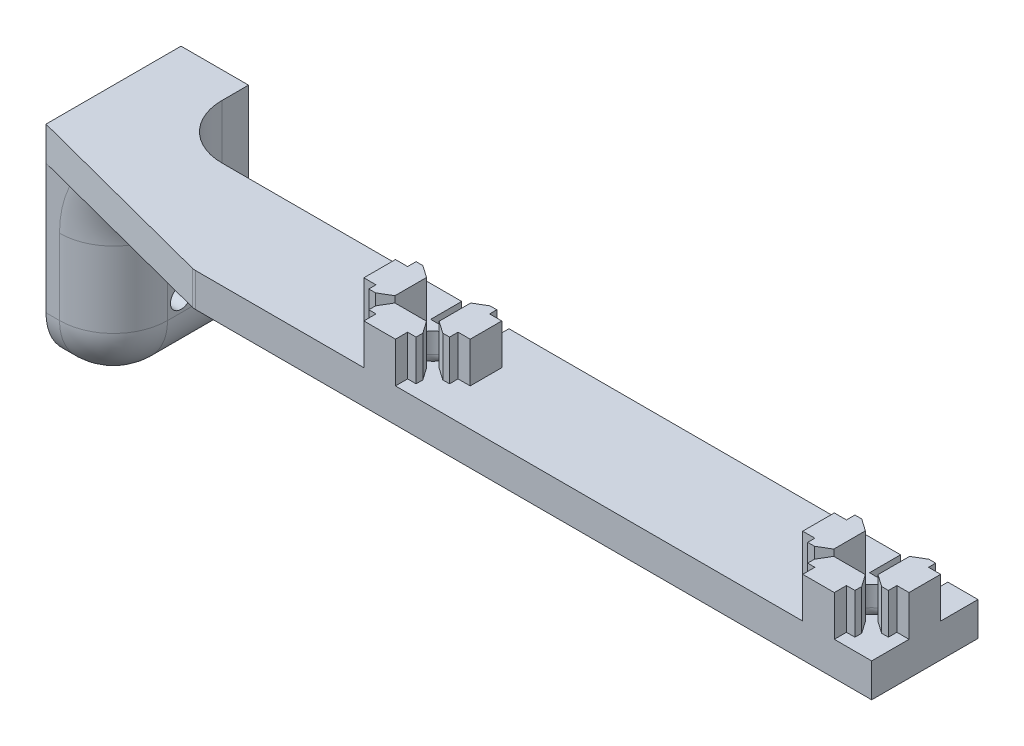
from build123d import *

# Parameters (mm, degrees)
BOSS_EXTRUDE1_DEPTH   = 7.62
BOSS_EXTRUDE1_2_DEPTH = 7.62
BOSS_EXTRUDE1_3_DEPTH = 7.62
BOSS_EXTRUDE1_4_DEPTH = 7.62
SKETCH2_W             = 165.1
SKETCH2_H             = 20
BOSS_EXTRUDE2_DEPTH   = 6.35
LPATTERN2_COUNT       = 2
LPATTERN2_PITCH       = 82.55
CUT_EXTRUDE1_DEPTH    = 157.048617104
FILLET1_R             = 2.54
SKETCH13_R            = 3.5
CUT_EXTRUDE5_DEPTH    = 156.608722121
FILLET6_R             = 2.54
SKETCH14_W            = 8.89
SKETCH14_H            = 5.842
CUT_EXTRUDE6_DEPTH    = 157.048617104
SKETCH15_W            = 25.4
SKETCH15_H            = 40.894
BOSS_EXTRUDE3_DEPTH   = 12.7
FILLET15_R            = 10.16
FILLET16_R            = 10.16
FILLET17_R            = 10.16
FILLET18_R            = 10.16
SKETCH18_R            = 1.984375
CUT_EXTRUDE9_DEPTH    = 12.7


with BuildPart() as part:
    # Sketch1 → Boss-Extrude1 (new body)
    with BuildSketch(Plane(origin=(0, 0, 0), x_dir=(1, 0, 0), z_dir=(0, 1, 0))):
        Polygon((2.9718, 10), (-2.9718, 10), (-2.9718, 7.714), (-4.567901235, 7.714), (-4.567901235, 6.444), (-2.9718, 4.158), (2.9718, 4.158), (4.322098765, 6.444), (4.322098765, 7.714), (2.9718, 7.714), align=None)
    boss_extrude1 = extrude(amount=BOSS_EXTRUDE1_DEPTH)



with BuildPart() as body_2:
    # Sketch1 → Boss-Extrude1 2 (new body)
    with BuildSketch(Plane(origin=(0, 0, 0), x_dir=(1, 0, 0), z_dir=(0, 1, 0))):
        Polygon((4.158, -2.9718), (4.158, 2.9718), (6.444, 4.322098765), (7.714, 4.322098765), (7.714, 2.9718), (10, 2.9718), (10, -2.9718), (7.714, -2.9718), (7.714, -4.567901235), (6.444, -4.567901235), align=None)
    boss_extrude1_2 = extrude(amount=BOSS_EXTRUDE1_2_DEPTH)


with BuildPart() as body_3:
    # Sketch1 → Boss-Extrude1 3 (new body)
    with BuildSketch(Plane(origin=(0, 0, 0), x_dir=(1, 0, 0), z_dir=(0, 1, 0))):
        Polygon((-10, -2.9718), (-10, 2.9718), (-7.714, 2.9718), (-7.714, 4.567901235), (-6.444, 4.567901235), (-4.158, 2.9718), (-4.158, -2.9718), (-6.444, -4.322098765), (-7.714, -4.322098765), (-7.714, -2.9718), align=None)
    boss_extrude1_3 = extrude(amount=BOSS_EXTRUDE1_3_DEPTH)


with BuildPart() as body_4:
    # Sketch1 → Boss-Extrude1 4 (new body)
    with BuildSketch(Plane(origin=(0, 0, 0), x_dir=(1, 0, 0), z_dir=(0, 1, 0))):
        Polygon((4.567901235, -6.444), (2.9718, -4.158), (-2.9718, -4.158), (-4.322098765, -6.444), (-4.322098765, -7.714), (-2.9718, -7.714), (-2.9718, -10), (2.9718, -10), (2.9718, -7.714), (4.567901235, -7.714), align=None)
    boss_extrude1_4 = extrude(amount=BOSS_EXTRUDE1_4_DEPTH)


with BuildPart() as part_1:
    add(part.part)

    add(body_2.part)  # Boss-Extrude2 merges body 2

    add(body_3.part)  # Boss-Extrude2 merges body 3

    add(body_4.part)  # Boss-Extrude2 merges body 4
    # Sketch2 → Boss-Extrude2 (add)
    with BuildSketch(Plane.XZ):
        with Locations((-72.55, 0)):
            Rectangle(SKETCH2_W, SKETCH2_H)
    extrude(amount=BOSS_EXTRUDE2_DEPTH)

    # LPattern2: Boss-Extrude1, Boss-Extrude1 2, Boss-Extrude1 3, Boss-Extrude1 4 ×2
    with Locations(*[(-i * LPATTERN2_PITCH, 0, 0) for i in range(1, LPATTERN2_COUNT)]):
        add(boss_extrude1)
        add(boss_extrude1_2)
        add(boss_extrude1_3)
        add(boss_extrude1_4)

    # Sketch4 → Cut-Extrude1 (cut, through all)
    with BuildSketch(Plane(origin=(0, -6.35, 0), x_dir=(-1, 0, 0), z_dir=(0, -1, 0))):
        Polygon((155.1, -10), (117.5588, -10), (155.1, -0.2108), align=None)
    extrude(amount=-CUT_EXTRUDE1_DEPTH, mode=Mode.SUBTRACT)

    # Fillet1
    fillet1_edges = [part_1.edges().sort_by_distance(p)[0] for p in [
        (-117.5588, -3.175, 10),
    ]]
    fillet(fillet1_edges, radius=FILLET1_R)

    # Sketch13 → Cut-Extrude5 (cut, through all)
    with BuildSketch(Plane(origin=(0, 0, 0), x_dir=(1, 0, 0), z_dir=(0, 1, 0))):
        with Locations(Location((0, 0, 0), (0, 0, 270))):
            Circle(SKETCH13_R)
        with Locations(Location((-82.55, 0, 0), (0, 0, 270))):
            Circle(SKETCH13_R)
    extrude(amount=-CUT_EXTRUDE5_DEPTH, mode=Mode.SUBTRACT)

    # Fillet6
    fillet6_edges = [part_1.edges().sort_by_distance(p)[0] for p in [
        (0, -6.35, -3.5),
        (-82.55, -6.35, -3.5),
    ]]
    fillet(fillet6_edges, radius=FILLET6_R)

    # Sketch14 → Cut-Extrude6 (cut, through all)
    with BuildSketch(Plane(origin=(0, 7.62, 0), x_dir=(1, 0, 0), z_dir=(0, 1, 0))):
        with Locations((-0.122901235, 7.079)):
            Rectangle(SKETCH14_W, SKETCH14_H)
        with Locations((-82.672901235, 7.079)):
            Rectangle(SKETCH14_W, SKETCH14_H)
    extrude(amount=-CUT_EXTRUDE6_DEPTH, mode=Mode.SUBTRACT)

    # Sketch15 → Boss-Extrude3 (add)
    with BuildSketch(Plane.ZY.offset(155.1)):
        with Locations((-12.4892, -20.447)):
            Rectangle(SKETCH15_W, SKETCH15_H)
    extrude(amount=-BOSS_EXTRUDE3_DEPTH)

    # Fillet15
    fillet15_edges = [part_1.edges().sort_by_distance(p)[0] for p in [
        (-142.4, -6.35, -4.8946),
    ]]
    fillet(fillet15_edges, radius=FILLET15_R)

    # Fillet16
    fillet16_edges = [part_1.edges().sort_by_distance(p)[0] for p in [
        (-142.4, -8.255, -10),
    ]]
    fillet(fillet16_edges, radius=FILLET16_R)

    # Fillet17
    fillet17_edges = [part_1.edges().sort_by_distance(p)[0] for p in [
        (-142.4, -40.894, -12.4892),
    ]]
    fillet(fillet17_edges, radius=FILLET17_R)

    # Fillet18
    fillet18_edges = [part_1.edges().sort_by_distance(p)[0] for p in [
        (-139.424204897, -9.325795103, 0.2108),
        (-153.83, -40.894, 0.2108),
        (-142.4, -23.622, 0.2108),
        (-145.375795103, -37.918204897, 0.2108),
    ]]
    fillet(fillet18_edges, radius=FILLET18_R)

    # Sketch18 → Cut-Extrude9 (cut)
    with BuildSketch(Plane.ZY.offset(155.1)):
        with Locations((-12.4892, -28.194)):
            Circle(SKETCH18_R)
    extrude(amount=-CUT_EXTRUDE9_DEPTH, mode=Mode.SUBTRACT)


solid = part_1.part
